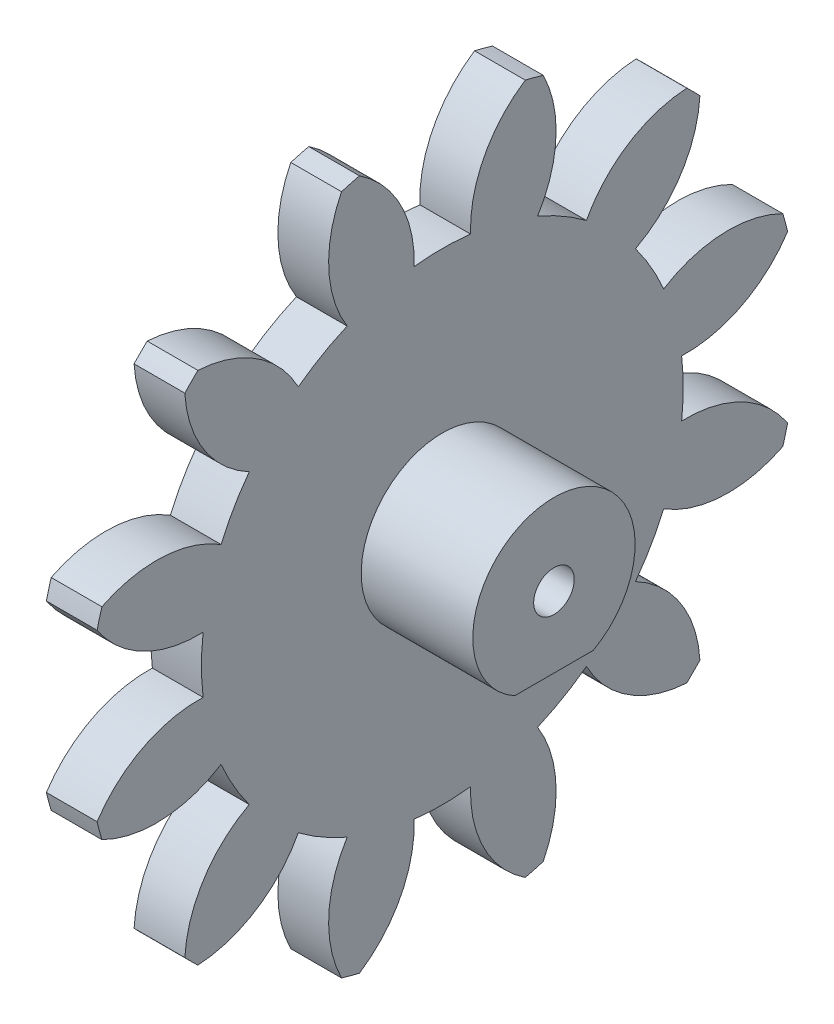
from build123d import *

# Parameters (mm, degrees)
BASPROSKE_W                     = 5
BASPROSKE_H                     = 35
TOOTHCUT_DEPTH                  = 50.749371855
TEETHCUTS_COUNT                 = 12
TEETHCUTS_ANGLE                 = 330
BORSKE_R                        = 0.4
BORE_DEPTH                      = 50.0000508
SKETCH1_R                       = 2
CUT_EXTRUDE1_DEPTH              = 49.388618122
SKETCH2_R                       = 2
BOSS_EXTRUDE1_DEPTH             = 11
M3X0_5_TAPPED_HOLE1_D           = 2.5
M3X0_5_TAPPED_HOLE1_DEPTH       = 7.5
M3X0_5_TAPPED_HOLE1_CSINK_D     = 3.45
M3X0_5_TAPPED_HOLE1_CSINK_ANGLE = 90
M3X0_5_TAPPED_HOLE1_TIP         = 0.751075774


with BuildPart() as part:
    # BasProSke → Base-Revolve (revolve)
    with BuildSketch(Plane(origin=(0, 0, 0), x_dir=(1, 0, 0), z_dir=(0, 1, 0)), mode=Mode.PRIVATE) as base_revolve_sk:
        with Locations((2.5, 17.5)):
            Rectangle(BASPROSKE_W, BASPROSKE_H)
    revolve(base_revolve_sk.sketch.rotate(Axis((-10, 0, 0), (1, 0, 0)), 180), axis=Axis((-10, 0, 0), (1, 0, 0)))

    # TooCutSke → ToothCut (cut, through all)
    with BuildSketch(Plane(origin=(0, 0, 0), x_dir=(0, 0, -1), z_dir=(1, 0, 0))):
        with BuildLine():
            ThreePointArc((2.779025365, 23.585843615), (0, 23.749), (-2.779025365, 23.585843615))
            ThreePointArc((-2.779025365, 23.585843615), (-4.116196739, 29.530367698), (-8.200466404, 34.051886819))
            ThreePointArc((-8.200466404, 34.051886819), (0, 35.0254), (8.200466404, 34.051886819))
            ThreePointArc((8.200466404, 34.051886819), (4.116196739, 29.530367698), (2.779025365, 23.585843615))
        make_face()
    toothcut = extrude(amount=TOOTHCUT_DEPTH, mode=Mode.SUBTRACT)

    # TeethCuts: ToothCut ×12 about axis
    teethcuts_axis = Axis((-10, 0, 0), (1, 0, 0))
    for i in range(1, TEETHCUTS_COUNT):
        add(toothcut.rotate(teethcuts_axis, i * TEETHCUTS_ANGLE / (TEETHCUTS_COUNT - 1)), mode=Mode.SUBTRACT)

    # BorSke → Bore (cut, symmetric)
    with BuildSketch(Plane(origin=(0, 0, 0), x_dir=(0, 0, -1), z_dir=(1, 0, 0))):
        with Locations(Location((0, 0, 0), (0, 0, 180))):
            Circle(BORSKE_R)
    extrude(amount=BORE_DEPTH, both=True, mode=Mode.SUBTRACT)

    # Sketch1 → Cut-Extrude1 (cut, through all)
    with BuildSketch(Plane(origin=(5, 0, 0), x_dir=(0, 0, -1), z_dir=(1, 0, 0))):
        Circle(SKETCH1_R)
    extrude(amount=-CUT_EXTRUDE1_DEPTH, mode=Mode.SUBTRACT)

    # Sketch2 → Boss-Extrude1 (add)
    with BuildSketch(Plane.ZY.offset(-5)):
        with BuildLine():
            Line((-3.872983346, -7), (3.872983346, -7))
            ThreePointArc((3.872983346, -7), (6.891439137, -4.063012013), (8, 0))
            ThreePointArc((8, 0), (-4.063012013, 6.891439137), (-3.872983346, -7))
        make_face()
        with Locations(Location((0, 0, 0), (0, 0, 180))):
            Circle(SKETCH2_R, mode=Mode.SUBTRACT)
    extrude(amount=-BOSS_EXTRUDE1_DEPTH)

    # M3x0.5 Tapped Hole1
    with Locations(Plane(origin=(0, -7, 0), x_dir=(-1, 0, 0), z_dir=(0, -1, 0))):
        with Locations((-12, 0)):
            CounterSinkHole(M3X0_5_TAPPED_HOLE1_D / 2, M3X0_5_TAPPED_HOLE1_CSINK_D / 2, depth=M3X0_5_TAPPED_HOLE1_DEPTH, counter_sink_angle=M3X0_5_TAPPED_HOLE1_CSINK_ANGLE)
            with Locations((0, 0, -(M3X0_5_TAPPED_HOLE1_DEPTH + M3X0_5_TAPPED_HOLE1_TIP / 2))):  # 118° drill point
                Cone(0, M3X0_5_TAPPED_HOLE1_D / 2, M3X0_5_TAPPED_HOLE1_TIP, mode=Mode.SUBTRACT)


solid = part.part
